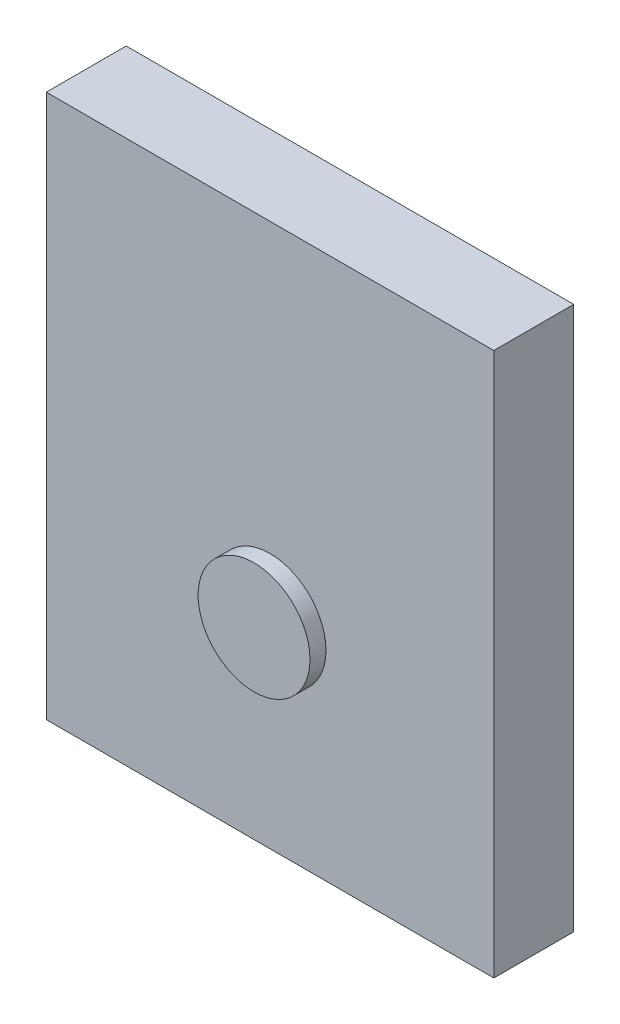
from build123d import *

# Parameters (mm, degrees)
SKETCH_1_W      = 56
SKETCH_1_H      = 68
EXTRUDE_1_DEPTH = 10
SKETCH_2_R      = 7
EXTRUDE_2_DEPTH = 2


with BuildPart() as part:
    # 草图1 → 凸台-拉伸1 (new body)
    with BuildSketch(Plane.XY):
        with Locations((36.502022567, -7.602070613)):
            Rectangle(SKETCH_1_W, SKETCH_1_H)
    extrude(amount=EXTRUDE_1_DEPTH)

    # 草图2 → 凸台-拉伸2 (add)
    with BuildSketch(Plane.XY.offset(10)):
        with Locations((36.502022567, -16.602070613)):
            Circle(SKETCH_2_R)
    extrude(amount=EXTRUDE_2_DEPTH)


solid = part.part
